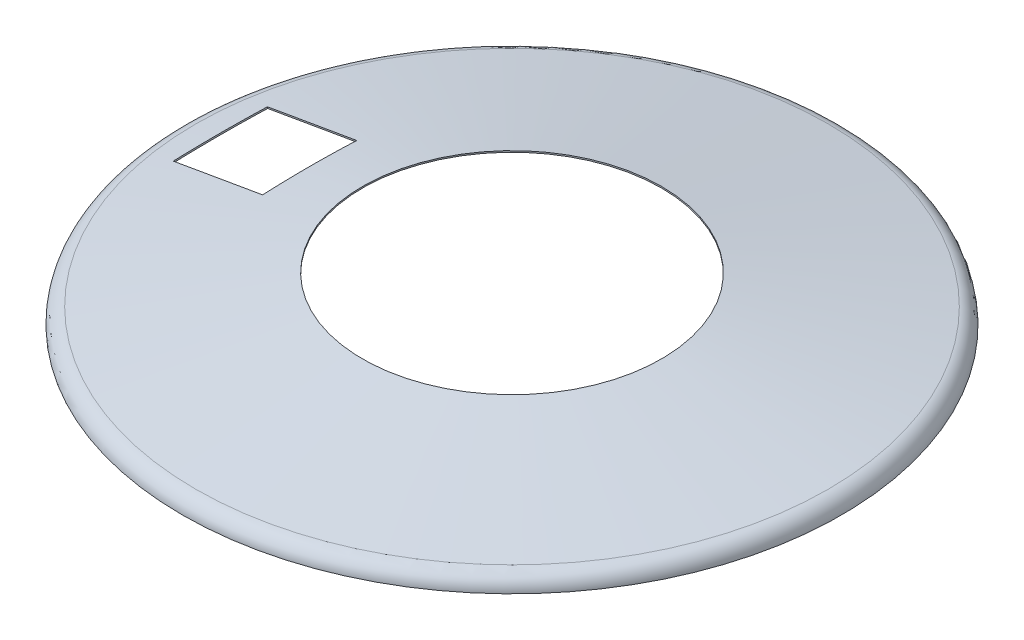
from build123d import *

# Parameters (mm, degrees)
SKETCH_2_R          = 317.5
CUT_EXTRUDE_2_DEPTH = 151
CUT_EXTRUDE_3_DEPTH = 772.950427912
SKETCH_4_W          = 192.600523864
SKETCH_4_H          = 200
CUT_EXTRUDE_4_DEPTH = 5


with BuildPart() as part:
    # Эскиз1 → Повернуть1 (revolve)
    with BuildSketch(Plane.XY):
        with BuildLine():
            Line((-671.894470109, 33.485149277), (-10, 150))
            Line((-10, 150), (-9.479899696, 147.045428005))
            Line((-9.479899696, 147.045428005), (-671.374369805, 30.530577282))
            ThreePointArc((-671.374369805, 30.530577282), (-689.74453057, 19.929808529), (-697, 0))
            Line((-697, 0), (-700, 0))
            ThreePointArc((-700, 0), (-692.042388367, 21.858499677), (-671.894470109, 33.485149277))
        make_face()
    revolve(axis=Axis((0, 73.50481492, 0), (0, -1, 0)))

    # Эскиз2 → Вырез-Вытянуть2 (cut, through all)
    with BuildSketch(Plane(origin=(0, 0, 0), x_dir=(1, 0, 0), z_dir=(0, 1, 0))):
        Circle(SKETCH_2_R)
    extrude(amount=CUT_EXTRUDE_2_DEPTH, mode=Mode.SUBTRACT)

    # Эскиз3 → Вырез-Вытянуть3 (cut, through all)
    with BuildSketch(Plane(origin=(-210.975213956, 365.419789709, 0), x_dir=(-0.866025404, -0.5, 0), z_dir=(0.5, -0.866025404, 0))):
        with BuildLine():
            Line((335.939579419, 95.5), (335.939579419, -95.5))
            ThreePointArc((335.939579419, -95.5), (337.111152294, -98.328427125), (339.939579419, -99.5))
            Line((339.939579419, -99.5), (425.439579419, -99.5))
            Line((425.439579419, -99.5), (510.939579419, -99.5))
            ThreePointArc((510.939579419, -99.5), (513.768006544, -98.328427125), (514.939579419, -95.5))
            Line((514.939579419, -95.5), (514.939579419, 95.5))
            ThreePointArc((514.939579419, 95.5), (513.768006544, 98.328427125), (510.939579419, 99.5))
            Line((510.939579419, 99.5), (425.439579419, 99.5))
            Line((425.439579419, 99.5), (339.939579419, 99.5))
            ThreePointArc((339.939579419, 99.5), (337.111152294, 98.328427125), (335.939579419, 95.5))
        make_face()
    extrude(amount=CUT_EXTRUDE_3_DEPTH, mode=Mode.SUBTRACT)

    # Эскиз4 → Вырез-Вытянуть4 (cut)
    with BuildSketch(Plane(origin=(-25.91179023, 147.199009892, 0), x_dir=(0.984857332, 0.173366768, 0), z_dir=(-0.173366768, 0.984857332, 0))):
        with Locations((-506.692199983, 0)):
            Rectangle(SKETCH_4_W, SKETCH_4_H)
    extrude(amount=-CUT_EXTRUDE_4_DEPTH, mode=Mode.SUBTRACT)


solid = part.part
